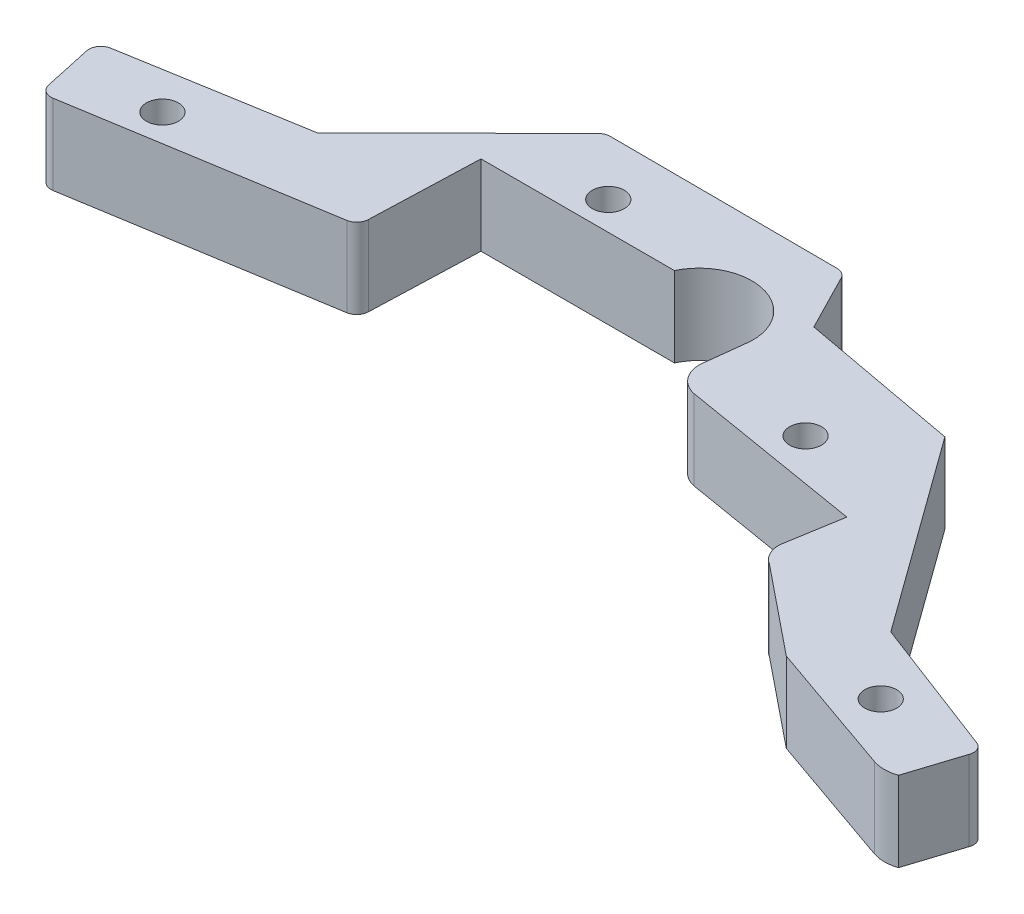
from build123d import *

# Parameters (mm, degrees)
SKETCH1_R           = 1
BOSS_EXTRUDE1_DEPTH = 5
FILLET1_R           = 0.75


with BuildPart() as part:
    # Sketch1 → Boss-Extrude1 (new body)
    with BuildSketch(Plane(origin=(0, 0, 0), x_dir=(1, 0, 0), z_dir=(0, 1, 0))):
        with BuildLine():
            Line((17.35965567, 10.202030332), (29.447075717, 10.202030332))
            ThreePointArc((29.447075717, 10.202030332), (31.66677099, 11.984583247), (34.447841937, 11.376153807))
            ThreePointArc((34.447841937, 11.376153807), (35.368803472, 10.219084334), (35.659625363, 8.769117942))
            Line((35.659625363, 8.769117942), (35.368803472, 6.25123518))
            ThreePointArc((35.368803472, 6.25123518), (35.604797827, 4.927222302), (36.70788952, 4.157877025))
            Line((36.70788952, 4.157877025), (48.178757035, 2.245683648))
            Line((48.178757035, 2.245683648), (47.58886704, -1.292949037))
            ThreePointArc((47.58886704, -1.292949037), (47.751350099, -2.119984122), (48.327597047, -2.73506723))
            Line((48.327597047, -2.73506723), (53.807205044, -7.165448567))
            Line((53.807205044, -7.165448567), (62.256251854, -10.114363821))
            ThreePointArc((62.256251854, -10.114363821), (63.012595107, -10.242357854), (63.768803253, -10.11356799))
            Line((63.768803253, -10.11356799), (64.838933553, -6.777694818))
            ThreePointArc((64.838933553, -6.777694818), (64.82438131, -6.262093226), (64.449505937, -5.907797834))
            Line((64.449505937, -5.907797834), (55.769751742, -2.596216357))
            Line((55.769751742, -2.596216357), (46.89988124, 9.654677352))
            Line((46.89988124, 9.654677352), (36.858577183, 11.505687421))
            Line((36.858577183, 11.505687421), (34.863073504, 15.401227244))
            Line((34.863073504, 15.401227244), (19.873257266, 15.461670051))
            Line((19.873257266, 15.461670051), (10.836196027, 6.49719565))
            Line((10.836196027, 6.49719565), (-0.977680405, 4.492963372))
            Line((-0.977680405, 4.492963372), (0, 0))
            Line((0, 0), (17.101259036, 2.779786934))
            Line((17.101259036, 2.779786934), (17.35965567, 10.202030332))
        make_face()
        with Locations((59.08099239, -6.537460134)):
            Circle(SKETCH1_R, mode=Mode.SUBTRACT)
        with Locations((23.534477486, 11.983797813)):
            Circle(SKETCH1_R, mode=Mode.SUBTRACT)
        with Locations((4.870081777, 2.779786934)):
            Circle(SKETCH1_R, mode=Mode.SUBTRACT)
        with Locations((42.49591928, 5.349768569)):
            Circle(SKETCH1_R, mode=Mode.SUBTRACT)
    extrude(amount=BOSS_EXTRUDE1_DEPTH)

    # Fillet1
    fillet1_edges = [part.edges().sort_by_distance(p)[0] for p in [
        (17.101259036, 2.5, -2.779786934),
        (0, 2.5, 0),
        (-0.977680405, 2.5, -4.492963372),
        (19.873257266, 2.5, -15.461670051),
        (34.863073504, 2.5, -15.401227244),
    ]]
    fillet(fillet1_edges, radius=FILLET1_R)


solid = part.part
